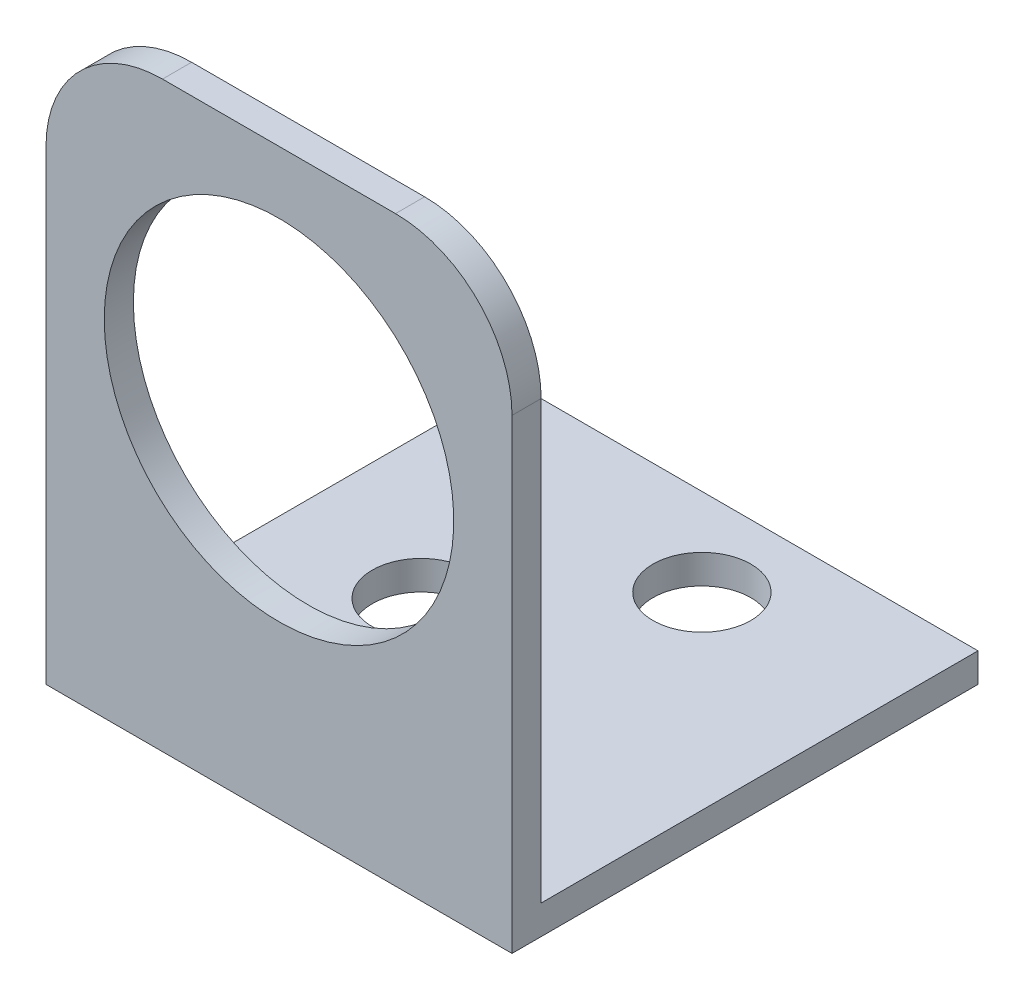
from build123d import *

# Parameters (mm, degrees)
BOSS_EXTRUDE1_DEPTH = 25.4
CUT_EXTRUDE1_REACH  = 3.587
SKETCH2_R           = 9.525
FILLET1_R           = 6.35
CUT_EXTRUDE2_REACH  = 33.75
SKETCH3_R           = 2.667


with BuildPart() as part:
    # Sketch1 → Boss-Extrude1 (new body)
    with BuildSketch(Plane(origin=(0, 0, 0), x_dir=(0, 0, -1), z_dir=(1, 0, 0))):
        Polygon((1.5875, 1.5875), (25.4, 1.5875), (25.4, 0), (0, 0), (0, 31.75), (1.5875, 31.75), align=None)
    extrude(amount=BOSS_EXTRUDE1_DEPTH)

    # Sketch2 → Cut-Extrude1 (cut, up to next)
    with BuildSketch(Plane(origin=(0, 0, -1.5875), x_dir=(-1, 0, 0), z_dir=(0, 0, -1)), mode=Mode.PRIVATE) as cut_extrude1_sk1:
        with Locations((-12.7, 18.830747356)):
            Circle(SKETCH2_R)
    cut_extrude1_tool1 = extrude(cut_extrude1_sk1.sketch, amount=-CUT_EXTRUDE1_REACH, mode=Mode.PRIVATE) & part.part
    add(cut_extrude1_tool1.solids().sort_by_distance((12.7, 18.830747, -1.5875))[0], mode=Mode.SUBTRACT)

    # Fillet1
    fillet1_edges = [part.edges().sort_by_distance(p)[0] for p in [
        (25.4, 31.75, -0.79375),
        (0, 31.75, -0.79375),
    ]]
    fillet(fillet1_edges, radius=FILLET1_R)

    # Sketch3 → Cut-Extrude2 (cut, up to next)
    with BuildSketch(Plane.XZ, mode=Mode.PRIVATE) as cut_extrude2_sk1:
        with Locations((15.113, -20.6375)):
            Circle(SKETCH3_R)
    cut_extrude2_tool1 = extrude(cut_extrude2_sk1.sketch, amount=-CUT_EXTRUDE2_REACH, mode=Mode.PRIVATE) & part.part
    add(cut_extrude2_tool1.solids().sort_by_distance((15.113, 0, -20.6375))[0], mode=Mode.SUBTRACT)
    # Sketch3 → Cut-Extrude2 (cut, up to next)
    with BuildSketch(Plane.XZ, mode=Mode.PRIVATE) as cut_extrude2_sk2:
        with Locations((7.747, -12.7)):
            Circle(SKETCH3_R)
    cut_extrude2_tool2 = extrude(cut_extrude2_sk2.sketch, amount=-CUT_EXTRUDE2_REACH, mode=Mode.PRIVATE) & part.part
    add(cut_extrude2_tool2.solids().sort_by_distance((7.747, 0, -12.7))[0], mode=Mode.SUBTRACT)


solid = part.part
